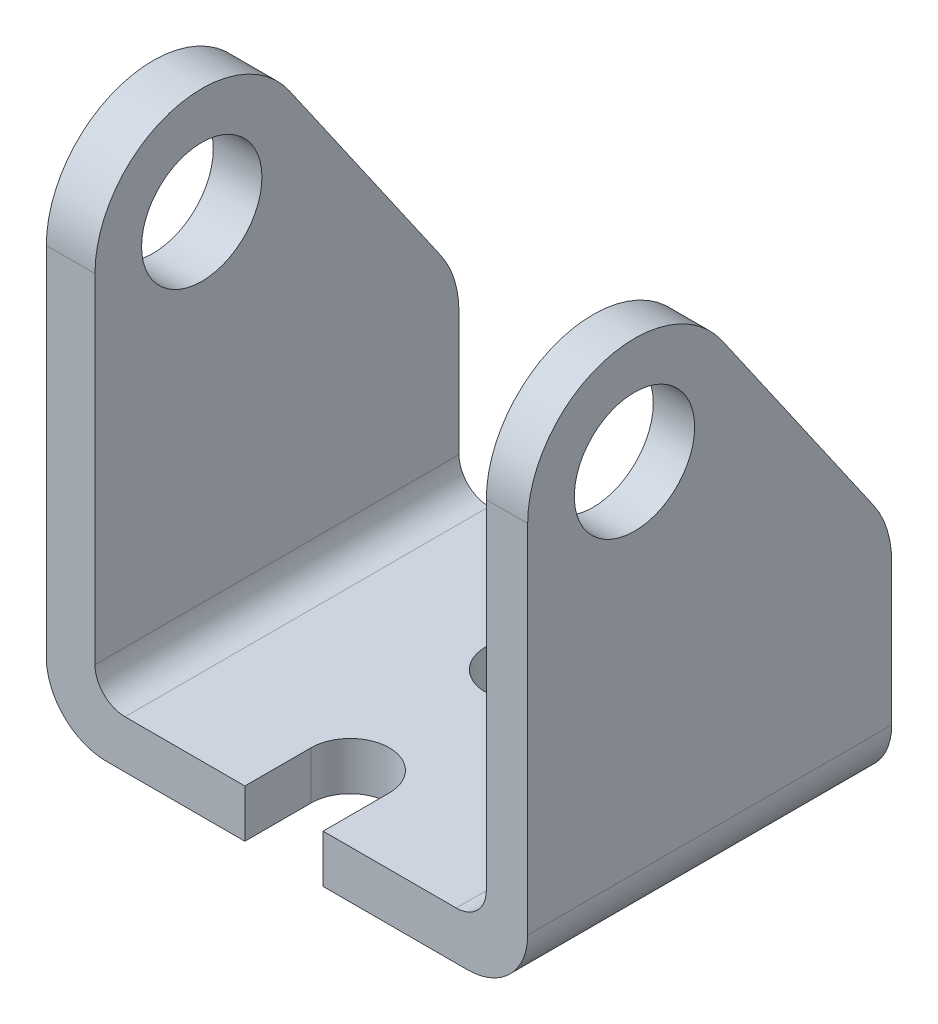
from build123d import *

# Parameters (mm, degrees)
BOSS_EXTRUDE1_DEPTH      = 30.734
SKETCH2_R                = 3.302
CUT_EXTRUDE3_DEPTH       = 45.196
FILLET3_R                = 5.08
FILLET4_R                = 2.54
SKETCH3_R                = 5.08
CUT_EXTRUDE5_DEPTH       = 41.64
CUT_EXTRUDE5_DEPTH_BACK  = 1
CUT_EXTRUDE14_DEPTH      = 41.64
CUT_EXTRUDE14_DEPTH_BACK = 1


with BuildPart() as part:
    # Sketch1 → Boss-Extrude1 (new body)
    with BuildSketch(Plane.XY):
        Polygon((0, 0), (40.64, 0), (40.64, 44.196), (37.147341265, 44.196), (37.147341265, 4.043206852), (4.107237524, 4.043206852), (4.107237524, 44.196), (0, 44.196), align=None)
    extrude(amount=BOSS_EXTRUDE1_DEPTH)

    # Sketch2 → Cut-Extrude3 (cut, through all)
    with BuildSketch(Plane.XZ):
        with Locations(Location((20.066, 10.414, 0), (0, 0, 270))):  # turned: the seam where the file's is
            Circle(SKETCH2_R)
        with BuildLine():
            Line((16.764, 30.734), (23.368, 30.734))
            Line((23.368, 30.734), (23.368, 25.146))
            ThreePointArc((23.368, 25.146), (20.066, 21.844), (16.764, 25.146))
            Line((16.764, 25.146), (16.764, 30.734))
        make_face()
    extrude(amount=-CUT_EXTRUDE3_DEPTH, mode=Mode.SUBTRACT)

    # Fillet3
    fillet3_edges = [part.edges().sort_by_distance(p)[0] for p in [
        (40.64, 0, 15.367),
        (0, 0, 15.367),
    ]]
    fillet(fillet3_edges, radius=FILLET3_R)

    # Fillet4
    fillet4_edges = [part.edges().sort_by_distance(p)[0] for p in [
        (4.107237524, 4.043206852, 15.367),
        (37.147341265, 4.043206852, 15.367),
    ]]
    fillet(fillet4_edges, radius=FILLET4_R)

    # Sketch3 → Cut-Extrude5 (cut, two sides)
    with BuildSketch(Plane(origin=(0, 0, 0), x_dir=(0, 0, -1), z_dir=(1, 0, 0))) as cut_extrude5_sk:
        with Locations((-21.717, 35.179)):
            Circle(SKETCH3_R)
    extrude(amount=CUT_EXTRUDE5_DEPTH, mode=Mode.SUBTRACT)
    extrude(cut_extrude5_sk.sketch, amount=-CUT_EXTRUDE5_DEPTH_BACK, mode=Mode.SUBTRACT)

    # Sketch6 → Cut-Extrude14 (cut, two sides)
    with BuildSketch(Plane(origin=(0, 0, 0), x_dir=(0, 0, -1), z_dir=(1, 0, 0))) as cut_extrude14_sk:
        with BuildLine():
            Line((-30.734, 44.196), (-30.734, 35.179))
            ThreePointArc((-30.734, 35.179), (-28.092981846, 41.554981846), (-21.717, 44.196))
            Line((-21.717, 44.196), (-30.734, 44.196))
        make_face()
        with BuildLine():
            Line((0, 44.196), (-21.717, 44.196))
            ThreePointArc((-21.717, 44.196), (-17.535826364, 43.167997185), (-14.308020426, 40.318388162))
            Line((-14.308020426, 40.318388162), (-1.524, 21.888850787))
            ThreePointArc((-1.524, 21.888850787), (-0.389894225, 19.569850475), (0, 17.018))
            Line((0, 17.018), (0, 44.196))
        make_face()
    extrude(amount=CUT_EXTRUDE14_DEPTH, mode=Mode.SUBTRACT)
    extrude(cut_extrude14_sk.sketch, amount=-CUT_EXTRUDE14_DEPTH_BACK, mode=Mode.SUBTRACT)


solid = part.part
